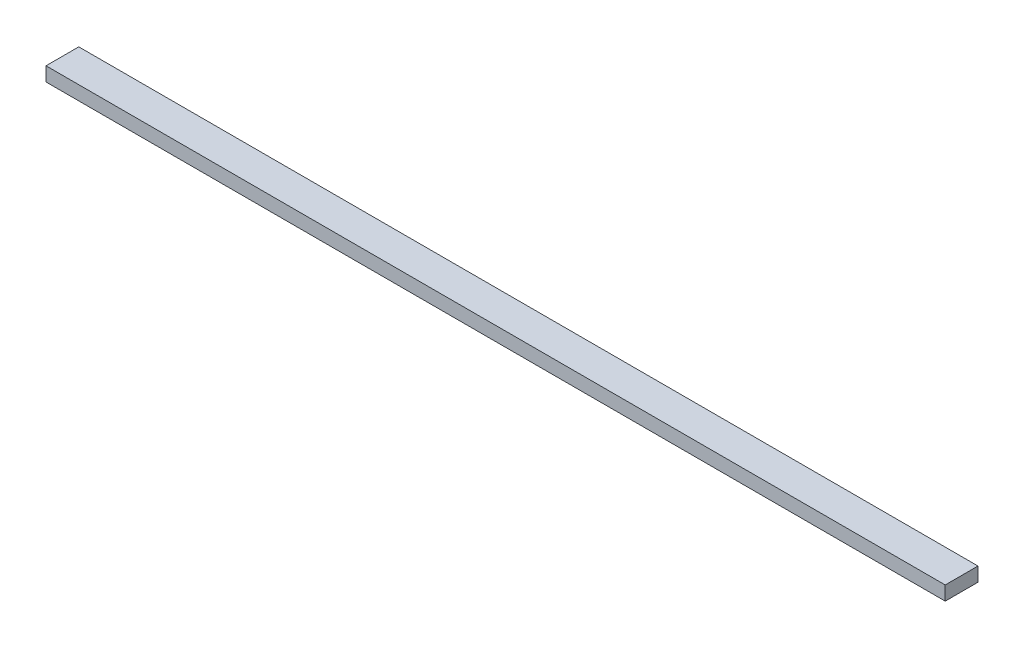
from build123d import *

# Parameters (mm, degrees)
SKETCH1_W           = 2438.4
SKETCH1_H           = 38.1
BOSS_EXTRUDE1_DEPTH = 88.9


with BuildPart() as part:
    # Sketch1 → Boss-Extrude1 (new body)
    with BuildSketch(Plane.XY):
        with Locations((-1219.2, -19.05)):
            Rectangle(SKETCH1_W, SKETCH1_H)
    extrude(amount=BOSS_EXTRUDE1_DEPTH)


solid = part.part
